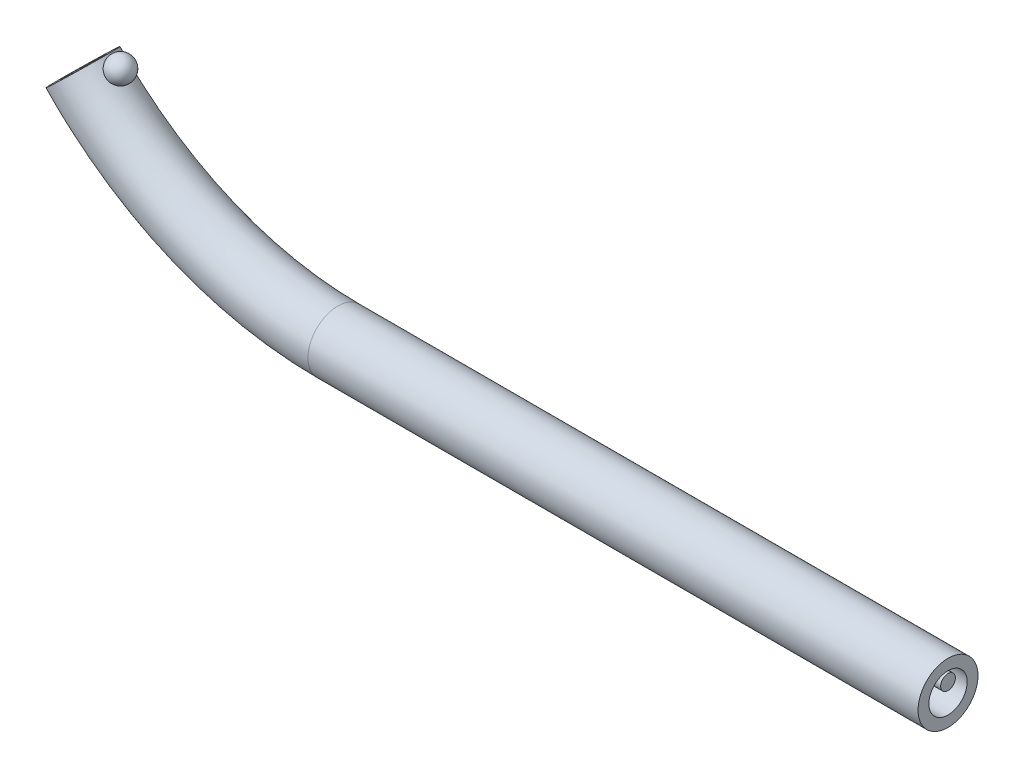
from build123d import *

# Parameters (mm, degrees)
SKETCH5_R           = 0.61
SKETCH5_R_2         = 0.39
SKETCH5_2_R         = 0.61
SKETCH5_2_R_2       = 0.39
BOSS_EXTRUDE2_DEPTH = 10
SKETCH8_R           = 0.15


with BuildPart() as part:
    # Sweep2: sweep along a path in Sketch4
    with BuildLine(Plane.XY) as sweep2_path:
        Line((-65.954222951, 0), (-68.364968213, 0))
        ThreePointArc((-68.364968213, 0), (-71.186123393, 0.579815367), (-73.549932813, 2.225265895))
    # Sketch5 → Sweep2 (sweep)
    with BuildSketch(Plane(origin=(-65.954222951, 0, 0), x_dir=(0, 0, -1), z_dir=(1, 0, 0))):
        Circle(SKETCH5_R)
        Circle(SKETCH5_R_2, mode=Mode.SUBTRACT)
    sweep(path=sweep2_path.line)

    # Sketch5_2 → Boss-Extrude2 (add)
    with BuildSketch(Plane(origin=(-65.954222951, 0, 0), x_dir=(0, 0, -1), z_dir=(1, 0, 0))):
        Circle(SKETCH5_2_R)
        Circle(SKETCH5_2_R_2, mode=Mode.SUBTRACT)
    extrude(amount=BOSS_EXTRUDE2_DEPTH)

    # Sketch6 → Revolve2 (revolve)
    with BuildSketch(Plane.XY):
        with BuildLine():
            Line((-72.949063517, 2.38792888), (-72.625665662, 2.76926053))
            ThreePointArc((-72.625665662, 2.76926053), (-72.596698765, 2.416895777), (-72.949063517, 2.38792888))
        make_face()
    revolve(axis=Axis((-72.949063517, 2.38792888, 0), (0.6467957105420484, 0.7626632997754689, 0)))


with BuildPart() as body_2:
    # Sweep3: sweep along a path in Sketch7
    with BuildLine(Plane.XY) as sweep3_path:
        Line((-55.954222951, 0.19), (-68.364968213, 0.19))
        ThreePointArc((-68.364968213, 0.19), (-71.111189458, 0.754414638), (-73.412212703, 2.356159635))
    # Sketch8 → Sweep3 (sweep)
    with BuildSketch(Plane(origin=(-36.018221468, 37.89664365, 0), x_dir=(0.7248426853938525, 0.688914422429251, 0), z_dir=(-0.688914422429251, 0.7248426853938525, 0))):
        with Locations((-51.589113042, 0)):
            Circle(SKETCH8_R)
    sweep(path=sweep3_path.line)


solid = Compound([part.part, body_2.part])
